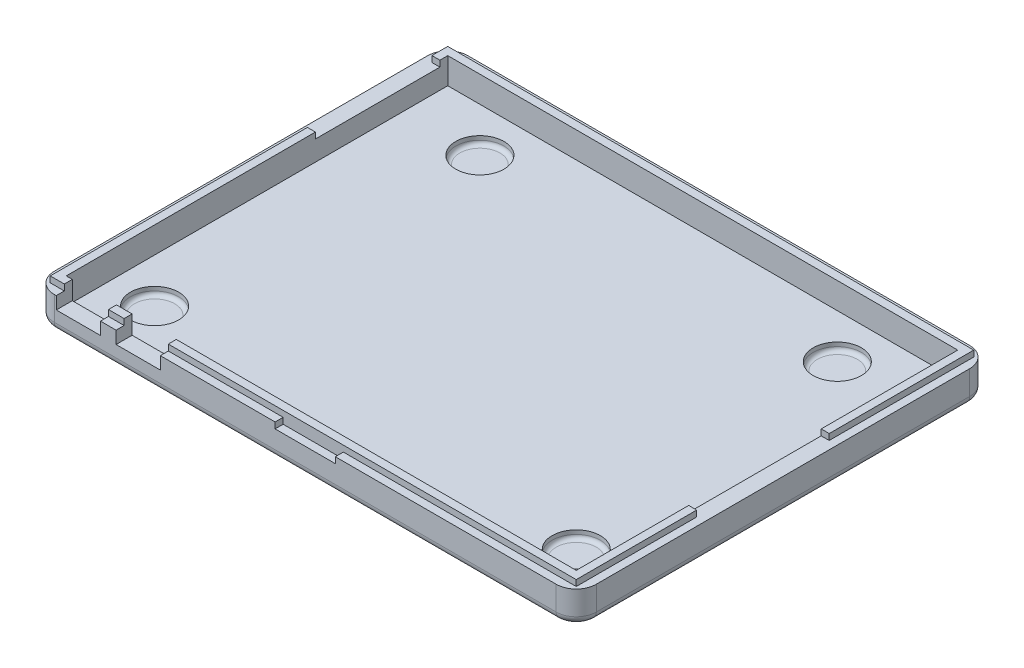
from build123d import *

# Parameters (mm, degrees)
SKETCH1_W                                      = 135
SKETCH1_H                                      = 103
BOSS_EXTRUDE1_DEPTH                            = 13
SKETCH2_W                                      = 127.02
SKETCH2_H                                      = 95.02
CUT_EXTRUDE1_DEPTH                             = 10
SKETCH3_R                                      = 6
CUT_EXTRUDE2_DEPTH                             = 2
FILLET1_R                                      = 1
FILLET1_OF_MIRROR1_R                           = 1
SKETCH4_R                                      = 6
CUT_EXTRUDE3_DEPTH                             = 2
FILLET2_R                                      = 1
FILLET2_OF_MIRROR2_R                           = 1
SKETCH5_W                                      = 31
SKETCH5_H                                      = 2.5
CUT_EXTRUDE4_DEPTH                             = 5
SKETCH6_W                                      = 135
SKETCH6_H                                      = 103
CUT_EXTRUDE5_DEPTH                             = 3.5
SKETCH7_W                                      = 33
SKETCH7_H                                      = 12
CUT_EXTRUDE6_DEPTH                             = 5
SKETCH8_OUTSIDE_W                              = 171.014
SKETCH8_OUTSIDE_H                              = 139.014
SKETCH8_OUTSIDE_W_2                            = 131
SKETCH8_OUTSIDE_H_2                            = 99
CUT_AROUND_SIDE_FOR_FRICTION_FITTING_COV_DEPTH = 1.5
SKETCH9_W                                      = 15
SKETCH9_H                                      = 2
CUT_EXTRUDE8_DEPTH                             = 1.5
FILLET3_R                                      = 5
FILLET4_R                                      = 2
SKETCH14_W                                     = 8.2
SKETCH14_H                                     = 1.5
CUT_EXTRUDE13_DEPTH                            = 4
SKETCH16_W                                     = 8.2
SKETCH16_H                                     = 1.5
CUT_EXTRUDE14_DEPTH                            = 4
SKETCH17_W                                     = 1.99
SKETCH17_H                                     = 1.5
CUT_EXTRUDE15_DEPTH                            = 9.3
CUT_EXTRUDE15_DEPTH_BACK                       = 1.1
SKETCH18_W                                     = 1.99
SKETCH18_H                                     = 1.5
CUT_EXTRUDE16_DEPTH                            = 9.3
CUT_EXTRUDE16_DEPTH_BACK                       = 1.1
SKETCH19_W                                     = 10.4
SKETCH19_H                                     = 4.692472087
SKETCH19_W_2                                   = 10.469305177
SKETCH19_H_2                                   = 5.245813632
CUT_EXTRUDE17_DEPTH                            = 3.1
SKETCH23_W                                     = 3.99
SKETCH23_H                                     = 3.1
BOSS_EXTRUDE2_DEPTH                            = 0.069305
CUT_EXTRUDE20_DEPTH                            = 0.2
CUT_EXTRUDE21_DEPTH                            = 0.4
CUT_EXTRUDE22_DEPTH                            = 0.3
CUT_EXTRUDE23_DEPTH                            = 0.3
SCALE1_SCALE                                   = 1.015


with BuildPart() as part:
    # Sketch1 → Boss-Extrude1 (new body)
    with BuildSketch(Plane(origin=(0, 0, 0), x_dir=(1, 0, 0), z_dir=(0, 1, 0))):
        Rectangle(SKETCH1_W, SKETCH1_H)
    extrude(amount=BOSS_EXTRUDE1_DEPTH)

    # Sketch2 → Cut-Extrude1 (cut)
    with BuildSketch(Plane(origin=(0, 13, 0), x_dir=(1, 0, 0), z_dir=(0, 1, 0))):
        Rectangle(SKETCH2_W, SKETCH2_H)
    extrude(amount=-CUT_EXTRUDE1_DEPTH, mode=Mode.SUBTRACT)

    # Sketch3 → Cut-Extrude2 (cut)
    with BuildSketch(Plane(origin=(0, 3, 0), x_dir=(1, 0, 0), z_dir=(0, 1, 0))):
        with Locations((-52.51, -36.51)):
            Circle(SKETCH3_R)
    cut_extrude2 = extrude(amount=-CUT_EXTRUDE2_DEPTH, mode=Mode.SUBTRACT)

    # Fillet1
    fillet1_edges = [part.edges().sort_by_distance(p)[0] for p in [
        (-58.51, 1, 36.51),
    ]]
    fillet(fillet1_edges, radius=FILLET1_R)

    # Mirror1: Cut-Extrude2 across plane
    add(cut_extrude2.mirror(Plane(origin=(0, 0, 0), x_dir=(0, 0, 1), z_dir=(1, 0, 0))), mode=Mode.SUBTRACT)

    # Fillet1 of Mirror1
    fillet1_of_mirror1_edges = [part.edges().sort_by_distance(p)[0] for p in [
        (58.51, 1, 36.51),
    ]]
    fillet(fillet1_of_mirror1_edges, radius=FILLET1_OF_MIRROR1_R)

    # Sketch4 → Cut-Extrude3 (cut)
    with BuildSketch(Plane(origin=(0, 3, 0), x_dir=(1, 0, 0), z_dir=(0, 1, 0))):
        with Locations((-44.51, 36.51)):
            Circle(SKETCH4_R)
    cut_extrude3 = extrude(amount=-CUT_EXTRUDE3_DEPTH, mode=Mode.SUBTRACT)

    # Fillet2
    fillet2_edges = [part.edges().sort_by_distance(p)[0] for p in [
        (-50.51, 1, -36.51),
    ]]
    fillet(fillet2_edges, radius=FILLET2_R)

    # Mirror2: Cut-Extrude3 across plane
    add(cut_extrude3.mirror(Plane(origin=(0, 0, 0), x_dir=(0, 0, 1), z_dir=(1, 0, 0))), mode=Mode.SUBTRACT)

    # Fillet2 of Mirror2
    fillet2_of_mirror2_edges = [part.edges().sort_by_distance(p)[0] for p in [
        (50.51, 1, -36.51),
    ]]
    fillet(fillet2_of_mirror2_edges, radius=FILLET2_OF_MIRROR2_R)

    # Sketch5 → Cut-Extrude4 (cut)
    with BuildSketch(Plane.ZY.offset(67.5)):
        with Locations((-30.05, 9.25)):
            Rectangle(SKETCH5_W, SKETCH5_H)
    extrude(amount=-CUT_EXTRUDE4_DEPTH, mode=Mode.SUBTRACT)

    # Sketch6 → Cut-Extrude5 (cut)
    with BuildSketch(Plane(origin=(0, 13, 0), x_dir=(1, 0, 0), z_dir=(0, 1, 0))):
        Rectangle(SKETCH6_W, SKETCH6_H)
    extrude(amount=-CUT_EXTRUDE5_DEPTH, mode=Mode.SUBTRACT)

    # Sketch7 → Cut-Extrude6 (cut)
    with BuildSketch(Plane(origin=(67.5, 0, 0), x_dir=(0, 0, -1), z_dir=(1, 0, 0))):
        with Locations((-3, 14)):
            Rectangle(SKETCH7_W, SKETCH7_H)
    extrude(amount=-CUT_EXTRUDE6_DEPTH, mode=Mode.SUBTRACT)

    # Sketch8 outside → Cut Around side for friction fitting cover (cut)
    with BuildSketch(Plane(origin=(0, 9.5, 0), x_dir=(1, 0, 0), z_dir=(0, 1, 0))):
        Rectangle(SKETCH8_OUTSIDE_W, SKETCH8_OUTSIDE_H)
        Rectangle(SKETCH8_OUTSIDE_W_2, SKETCH8_OUTSIDE_H_2, mode=Mode.SUBTRACT)
    extrude(amount=-CUT_AROUND_SIDE_FOR_FRICTION_FITTING_COV_DEPTH, mode=Mode.SUBTRACT)

    # Sketch9 → Cut-Extrude8 (cut)
    with BuildSketch(Plane(origin=(0, 8, 0), x_dir=(1, 0, 0), z_dir=(0, 1, 0))):
        with Locations((0, -50.5)):
            Rectangle(SKETCH9_W, SKETCH9_H)
    extrude(amount=-CUT_EXTRUDE8_DEPTH, mode=Mode.SUBTRACT)

    # Fillet3
    fillet3_edges = [part.edges().sort_by_distance(p)[0] for p in [
        (67.5, 4, 51.5),
        (-67.5, 4, 51.5),
        (-67.5, 4, -51.5),
        (67.5, 4, -51.5),
    ]]
    fillet(fillet3_edges, radius=FILLET3_R)

    # Fillet4
    fillet4_edges = [part.edges().sort_by_distance(p)[0] for p in [
        (67.5, 0, 0),
        (0, 0, 51.5),
        (-67.5, 0, 0),
        (0, 0, -51.5),
        (-66.035533906, 0, 50.035533906),
        (-66.035533906, 0, -50.035533906),
        (66.035533906, 0, -50.035533906),
        (66.035533906, 0, 50.035533906),
    ]]
    fillet(fillet4_edges, radius=FILLET4_R)

    # Sketch14 → Cut-Extrude13 (cut)
    with BuildSketch(Plane.XY.offset(49.5)):
        with Locations((-56.5, 8.75)):
            Rectangle(SKETCH14_W, SKETCH14_H)
    extrude(amount=-CUT_EXTRUDE13_DEPTH, mode=Mode.SUBTRACT)

    # Sketch16 → Cut-Extrude14 (cut)
    with BuildSketch(Plane.XY.offset(49.5)):
        with Locations((-41.5, 8.75)):
            Rectangle(SKETCH16_W, SKETCH16_H)
    extrude(amount=-CUT_EXTRUDE14_DEPTH, mode=Mode.SUBTRACT)

    # Sketch17 → Cut-Extrude15 (cut, two sides)
    with BuildSketch(Plane(origin=(-60.6, 0, 0), x_dir=(0, 0, -1), z_dir=(1, 0, 0))) as cut_extrude15_sk:
        with Locations((-48.505, 8.75)):
            Rectangle(SKETCH17_W, SKETCH17_H)
    extrude(amount=CUT_EXTRUDE15_DEPTH, mode=Mode.SUBTRACT)
    extrude(cut_extrude15_sk.sketch, amount=-CUT_EXTRUDE15_DEPTH_BACK, mode=Mode.SUBTRACT)

    # Sketch18 → Cut-Extrude16 (cut, two sides)
    with BuildSketch(Plane(origin=(-45.6, 0, 0), x_dir=(0, 0, -1), z_dir=(1, 0, 0))) as cut_extrude16_sk:
        with Locations((-48.505, 8.75)):
            Rectangle(SKETCH18_W, SKETCH18_H)
    extrude(amount=CUT_EXTRUDE16_DEPTH, mode=Mode.SUBTRACT)
    extrude(cut_extrude16_sk.sketch, amount=-CUT_EXTRUDE16_DEPTH_BACK, mode=Mode.SUBTRACT)

    # Sketch19 → Cut-Extrude17 (cut)
    with BuildSketch(Plane(origin=(0, 8, 0), x_dir=(1, 0, 0), z_dir=(0, 1, 0))):
        with Locations((-56.5, -49.856236044)):
            Rectangle(SKETCH19_W, SKETCH19_H)
        with Locations((-41.465347412, -50.132906816)):
            Rectangle(SKETCH19_W_2, SKETCH19_H_2)
    extrude(amount=-CUT_EXTRUDE17_DEPTH, mode=Mode.SUBTRACT)

    # Sketch23 → Boss-Extrude2 (add)
    with BuildSketch(Plane.ZY.offset(36.230694823)):
        with Locations((49.505, 6.45)):
            Rectangle(SKETCH23_W, SKETCH23_H)
    extrude(amount=BOSS_EXTRUDE2_DEPTH)

    # Sketch24 → Cut-Extrude20 (cut)
    with BuildSketch(Plane.ZY.offset(36.3)):
        Polygon((47.51, 4.9), (47.51, 9.5), (49.5, 9.5), (49.5, 8), (51.5, 8), (51.5, 4.9), align=None)
    extrude(amount=-CUT_EXTRUDE20_DEPTH, mode=Mode.SUBTRACT)

    # Sketch25 → Cut-Extrude21 (cut)
    with BuildSketch(Plane(origin=(-46.7, 0, 0), x_dir=(0, 0, -1), z_dir=(1, 0, 0))):
        Polygon((-51.5, 4.9), (-47.51, 4.9), (-47.51, 9.5), (-49.5, 9.5), (-49.5, 8), (-51.5, 8), align=None)
    extrude(amount=-CUT_EXTRUDE21_DEPTH, mode=Mode.SUBTRACT)

    # Sketch26 → Cut-Extrude22 (cut)
    with BuildSketch(Plane.ZY.offset(51.3)):
        Polygon((47.51, 9.5), (47.51, 4.9), (51.5, 4.9), (51.5, 8), (49.5, 8), (49.5, 9.5), align=None)
    extrude(amount=-CUT_EXTRUDE22_DEPTH, mode=Mode.SUBTRACT)

    # Sketch27 → Cut-Extrude23 (cut)
    with BuildSketch(Plane(origin=(-61.7, 0, 0), x_dir=(0, 0, -1), z_dir=(1, 0, 0))):
        Polygon((-51.5, 4.9), (-47.51, 4.9), (-47.51, 9.5), (-49.5, 9.5), (-49.5, 8), (-51.5, 8), align=None)
    extrude(amount=-CUT_EXTRUDE23_DEPTH, mode=Mode.SUBTRACT)


with BuildPart() as part_1:
    # Scale1: scaled about (0, 0, 0)
    add(part.part.scale(SCALE1_SCALE))


solid = part_1.part
